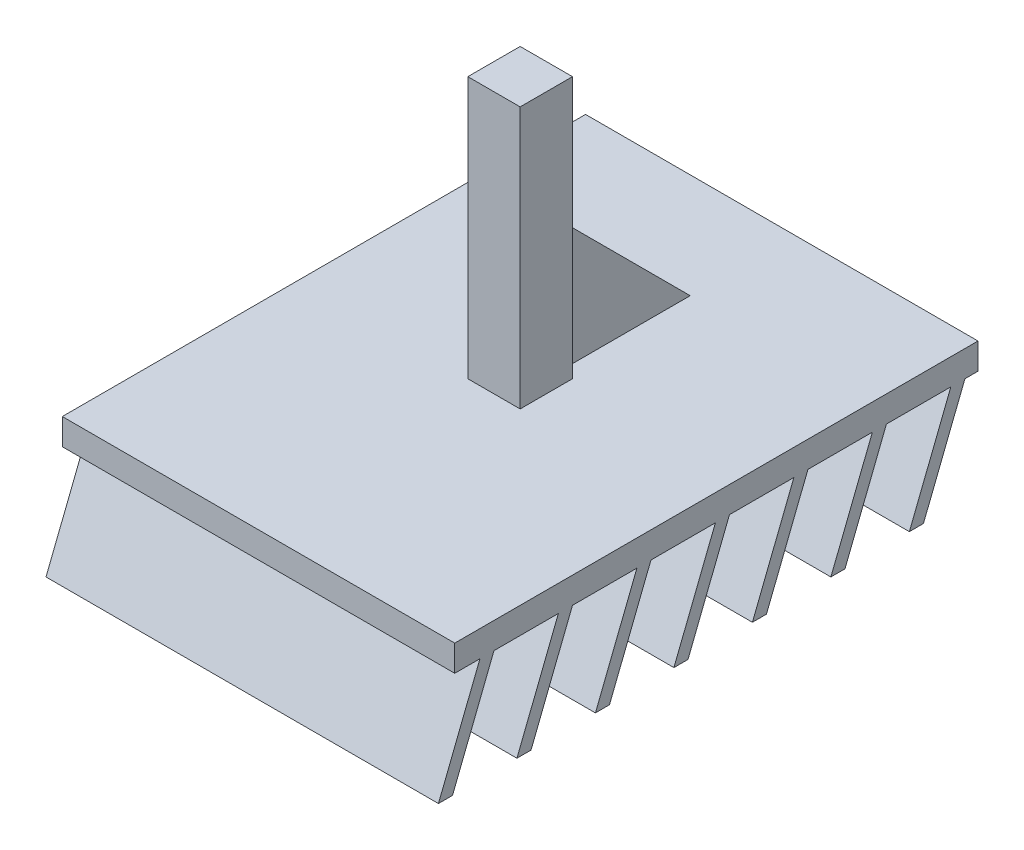
from build123d import *

# Parameters (mm, degrees)
ESQUISSE1_W                = 15
ESQUISSE1_H                = 1
BOSS_EXTRU_1_DEPTH         = 10
BOSS_EXTRU_1_DEPTH_BACK    = 10
ESQUISSE2_W                = 2
ESQUISSE2_H                = 10
BOSS_EXTRU_2_DEPTH         = 1
BOSS_EXTRU_2_DEPTH_BACK    = 1
BOSS_EXTRU_3_DEPTH         = 0.5
BOSS_EXTRU_3_DEPTH_BACK    = 0.5
BOSS_EXTRU_4_DEPTH         = 15
R_P_TITION_LIN_AIRE1_COUNT = 7
R_P_TITION_LIN_AIRE1_PITCH = 3


with BuildPart() as part:
    # Esquisse1 → Boss.-Extru.1 (new body, two sides)
    with BuildSketch(Plane.XY) as boss_extru_1_sk:
        with Locations((0, 0.5)):
            Rectangle(ESQUISSE1_W, ESQUISSE1_H)
    extrude(amount=BOSS_EXTRU_1_DEPTH)
    extrude(boss_extru_1_sk.sketch, amount=-BOSS_EXTRU_1_DEPTH_BACK)

    # Esquisse2 → Boss.-Extru.2 (add, two sides)
    with BuildSketch(Plane.XY) as boss_extru_2_sk:
        with Locations((0, 6)):
            Rectangle(ESQUISSE2_W, ESQUISSE2_H)
    extrude(amount=BOSS_EXTRU_2_DEPTH)
    extrude(boss_extru_2_sk.sketch, amount=-BOSS_EXTRU_2_DEPTH_BACK)

    # Esquisse3 → Boss.-Extru.3 (add, two sides)
    with BuildSketch(Plane(origin=(0, 0, 0), x_dir=(0, 0, -1), z_dir=(1, 0, 0))) as boss_extru_3_sk:
        Polygon((1, 6), (6, 1), (1, 1), align=None)
    extrude(amount=BOSS_EXTRU_3_DEPTH)
    extrude(boss_extru_3_sk.sketch, amount=-BOSS_EXTRU_3_DEPTH_BACK)

    # Esquisse4 → Boss.-Extru.4 (add)
    with BuildSketch(Plane.ZY.offset(7.5)):
        Polygon((-9.5, 0), (-7.914599878, -4), (-7.37675851, -4), (-8.962158632, 0), align=None)
    boss_extru_4 = extrude(amount=-BOSS_EXTRU_4_DEPTH)

    # R_p_tition lin_aire1: Boss.-Extru.4 ×7
    with Locations(*[(0, 0, i * R_P_TITION_LIN_AIRE1_PITCH) for i in range(1, R_P_TITION_LIN_AIRE1_COUNT)]):
        add(boss_extru_4)


solid = part.part
